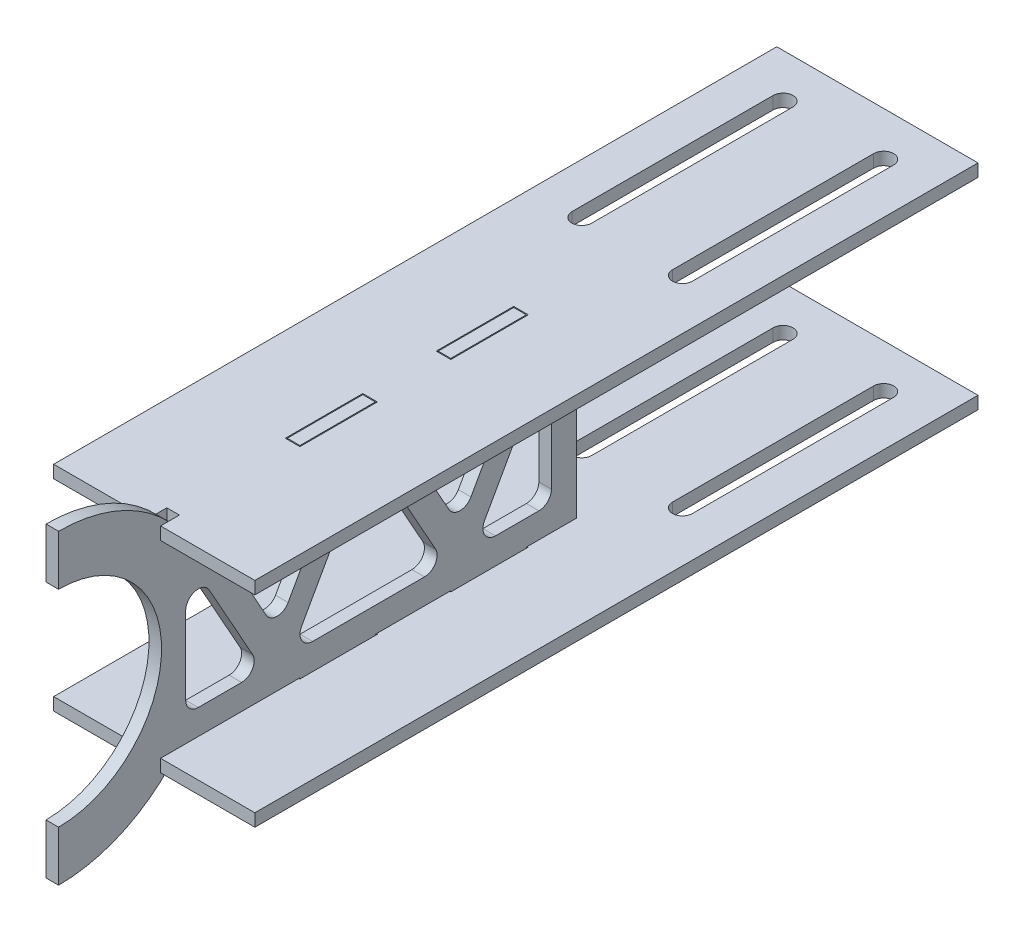
from build123d import *

# Parameters (mm, degrees)
BOSS_EXTRUDE1_DEPTH = 1.5875
SKETCH2_W           = 3.683
SKETCH2_H           = 19.558
BOSS_EXTRUDE2_DEPTH = 3.175
CUT_EXTRUDE1_DEPTH  = 27.9875
FILLET1_R           = 3.175


with BuildPart() as part:
    # Sketch1 → Boss-Extrude1 (new body, symmetric)
    with BuildSketch(Plane(origin=(0, 0, 0), x_dir=(0, 0, -1), z_dir=(1, 0, 0))):
        with BuildLine():
            Line((30.506636061, 23.8125), (60.925, 23.8125))
            Line((60.925, 23.8125), (60.925, 26.9875))
            Line((60.925, 26.9875), (79.975, 26.9875))
            Line((79.975, 26.9875), (79.975, 23.8125))
            Line((79.975, 23.8125), (99.025, 23.8125))
            Line((99.025, 23.8125), (99.025, 26.9875))
            Line((99.025, 26.9875), (118.075, 26.9875))
            Line((118.075, 26.9875), (118.075, 23.8125))
            Line((118.075, 23.8125), (130.775, 23.8125))
            Line((130.775, 23.8125), (130.775, -23.8125))
            Line((130.775, -23.8125), (118.075, -23.8125))
            Line((118.075, -23.8125), (118.075, -26.9875))
            Line((118.075, -26.9875), (99.025, -26.9875))
            Line((99.025, -26.9875), (99.025, -23.8125))
            Line((99.025, -23.8125), (79.975, -23.8125))
            Line((79.975, -23.8125), (79.975, -26.9875))
            Line((79.975, -26.9875), (60.925, -26.9875))
            Line((60.925, -26.9875), (60.925, -23.8125))
            Line((60.925, -23.8125), (30.506636061, -23.8125))
            ThreePointArc((30.506636061, -23.8125), (16.972717078, -34.779546791), (0, -38.7))
            Line((0, -38.7), (0, -26))
            ThreePointArc((0, -26), (26, 0), (0, 26))
            Line((0, 26), (0, 38.7))
            ThreePointArc((0, 38.7), (16.972717078, 34.779546791), (30.506636061, 23.8125))
        make_face()
    extrude(amount=BOSS_EXTRUDE1_DEPTH, both=True)

    # Sketch3 → Cut-Extrude1 (cut, through all)
    with BuildSketch(Plane(origin=(1.5875, 0, 0), x_dir=(0, 0, -1), z_dir=(1, 0, 0))):
        Polygon((32.094136061, -17.4625), (51.625664971, -17.4625), (32.094136061, 17.4625), align=None)
        Polygon((70.984031649, 17.4625), (39.369672442, 17.4625), (55.176852046, -10.802862644), align=None)
        Polygon((78.25956803, 17.4625), (58.72803912, -17.4625), (97.791096941, -17.4625), align=None)
        Polygon((117.149463618, 17.4625), (85.535104412, 17.4625), (101.342284015, -10.802862644), align=None)
        Polygon((104.89347109, -17.4625), (124.425, -17.4625), (124.425, 17.4625), align=None)
    extrude(amount=-CUT_EXTRUDE1_DEPTH, mode=Mode.SUBTRACT)

    # Fillet1
    fillet1_edges = [part.edges().sort_by_distance(p)[0] for p in [
        (0, -17.4625, -104.89347109),
        (0, 17.4625, -124.425),
        (0, -17.4625, -124.425),
        (0, -10.802862644, -101.342284015),
        (0, 17.4625, -85.535104412),
        (0, 17.4625, -117.149463618),
        (0, -17.4625, -32.094136061),
        (0, 17.4625, -32.094136061),
        (0, -17.4625, -51.625664971),
        (0, -17.4625, -58.72803912),
        (0, 17.4625, -78.25956803),
        (0, -17.4625, -97.791096941),
        (0, 17.4625, -39.369672442),
        (0, 17.4625, -70.984031649),
        (0, -10.802862644, -55.176852046),
    ]]
    fillet(fillet1_edges, radius=FILLET1_R)


with BuildPart() as body_2:
    # Sketch2 → Boss-Extrude2 (new body)
    with BuildSketch(Plane(origin=(0, 23.8125, 0), x_dir=(1, 0, 0), z_dir=(0, 1, 0))):
        Polygon((-1.5875, 30.506636061), (1.5875, 30.506636061), (1.5875, 25.744136061), (25.4, 25.744136061), (25.4, 208.306636061), (-25.4, 208.306636061), (-25.4, 25.744136061), (-1.5875, 25.744136061), align=None)
        with BuildLine():
            Line((10.19175, 146.394136061), (10.19175, 197.194136061))
            ThreePointArc((10.19175, 197.194136061), (12.7, 199.702386061), (15.20825, 197.194136061))
            Line((15.20825, 197.194136061), (15.20825, 146.394136061))
            ThreePointArc((15.20825, 146.394136061), (12.7, 143.885886061), (10.19175, 146.394136061))
        make_face(mode=Mode.SUBTRACT)
        with BuildLine():
            Line((-10.19175, 146.394136061), (-10.19175, 197.194136061))
            ThreePointArc((-10.19175, 197.194136061), (-12.7, 199.702386061), (-15.20825, 197.194136061))
            Line((-15.20825, 197.194136061), (-15.20825, 146.394136061))
            ThreePointArc((-15.20825, 146.394136061), (-12.7, 143.885886061), (-10.19175, 146.394136061))
        make_face(mode=Mode.SUBTRACT)
        with Locations((0, 108.55)):
            Rectangle(SKETCH2_W, SKETCH2_H, mode=Mode.SUBTRACT)
        with Locations((0, 70.45)):
            Rectangle(SKETCH2_W, SKETCH2_H, mode=Mode.SUBTRACT)
    extrude(amount=BOSS_EXTRUDE2_DEPTH)


with BuildPart() as body_3:
    # Mirror3: mirrored copy
    add(body_2.part.mirror(Plane.ZX))


solid = Compound([part.part, body_2.part, body_3.part])
